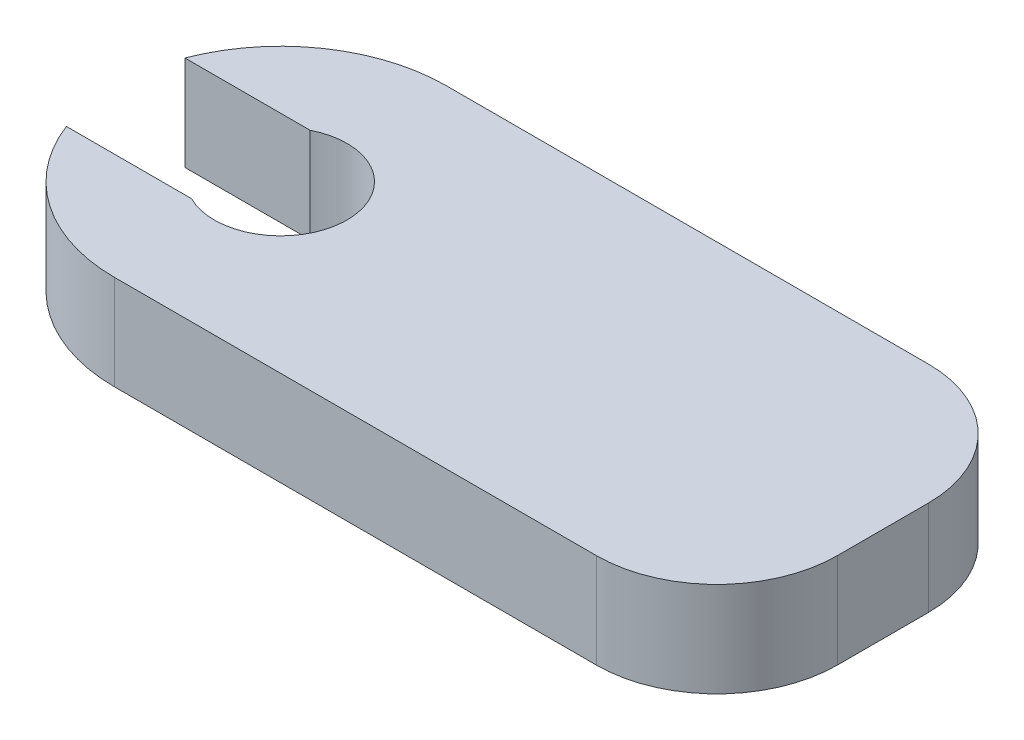
from build123d import *

# Parameters (mm, degrees)
BOSS_EXTRUDE1_DEPTH = 2


with BuildPart() as part:
    # Sketch1 → Boss-Extrude1 (new body)
    with BuildSketch(Plane(origin=(0, 0, 0), x_dir=(1, 0, 0), z_dir=(0, 1, 0))):
        with BuildLine():
            ThreePointArc((0, 3.5), (-1.984314586, 2.88313989), (-3.269175164, 1.2499975))
            Line((-3.269175164, 1.2499975), (-0.630480967, 1.2499975))
            ThreePointArc((-0.630480967, 1.2499975), (1.4, 0), (-0.630480967, -1.2499975))
            Line((-0.630480967, -1.2499975), (-3.269175164, -1.2499975))
            ThreePointArc((-3.269175164, -1.2499975), (-1.984314586, -2.88313989), (0, -3.5))
            Line((0, -3.5), (10.16, -3.5))
            ThreePointArc((10.16, -3.5), (11.956051224, -2.756051224), (12.7, -0.96))
            Line((12.7, -0.96), (12.7, 0.96))
            ThreePointArc((12.7, 0.96), (11.956051224, 2.756051224), (10.16, 3.5))
            Line((10.16, 3.5), (0, 3.5))
        make_face()
    extrude(amount=BOSS_EXTRUDE1_DEPTH)


solid = part.part
